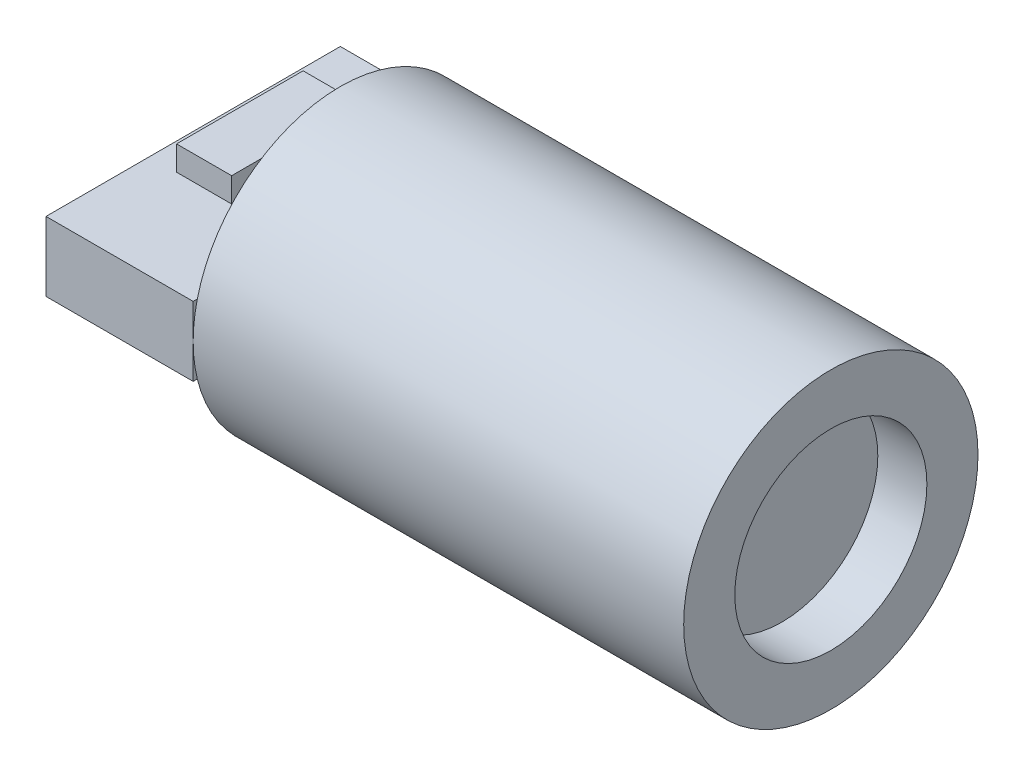
from build123d import *

# Parameters (mm, degrees)
SKETCH1_R           = 3
BOSS_EXTRUDE1_DEPTH = 10
SKETCH2_R           = 1.957866775
CUT_EXTRUDE1_DEPTH  = 1
SKETCH3_W           = 6
SKETCH3_H           = 1.413467244
BOSS_EXTRUDE2_DEPTH = 3
SKETCH4_W           = 1.123078493
SKETCH4_H           = 2.580406537
BOSS_EXTRUDE3_DEPTH = 0.5


with BuildPart() as part:
    # Sketch1 → Boss-Extrude1 (new body)
    with BuildSketch(Plane(origin=(0, 0, 0), x_dir=(0, 0, -1), z_dir=(1, 0, 0))):
        Circle(SKETCH1_R)
    extrude(amount=BOSS_EXTRUDE1_DEPTH)

    # Sketch2 → Cut-Extrude1 (cut)
    with BuildSketch(Plane(origin=(10, 0, 0), x_dir=(0, 0, -1), z_dir=(1, 0, 0))):
        Circle(SKETCH2_R)
    extrude(amount=-CUT_EXTRUDE1_DEPTH, mode=Mode.SUBTRACT)

    # Sketch3 → Boss-Extrude2 (add)
    with BuildSketch(Plane.ZY):
        Rectangle(SKETCH3_W, SKETCH3_H)
    extrude(amount=BOSS_EXTRUDE2_DEPTH)

    # Sketch4 → Boss-Extrude3 (add)
    with BuildSketch(Plane(origin=(0, 0.706733622, 0), x_dir=(1, 0, 0), z_dir=(0, 1, 0))):
        with Locations((-1.88810277, 0.401099462)):
            Rectangle(SKETCH4_W, SKETCH4_H)
    extrude(amount=BOSS_EXTRUDE3_DEPTH)


solid = part.part
